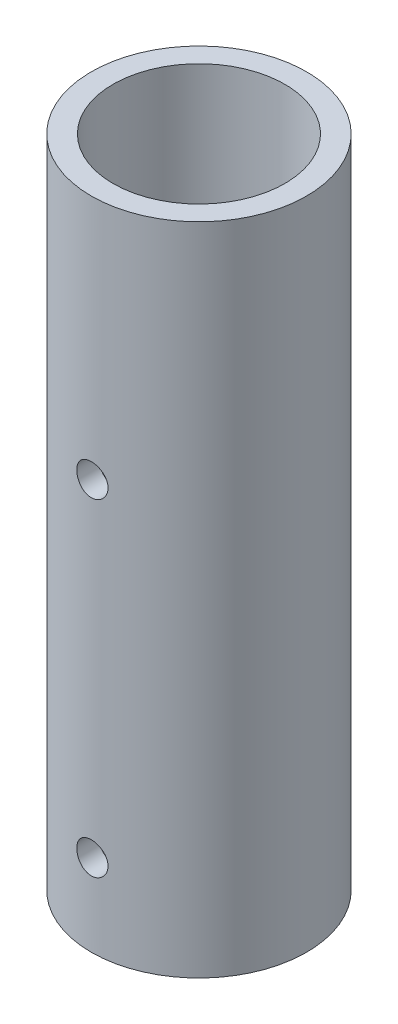
from build123d import *

# Parameters (mm, degrees)
SKETCH1_R               = 16.7005
SKETCH1_R_2             = 13.335
BOSS_EXTRUDE1_DEPTH     = 101.6
SKETCH2_R               = 2.4257
CUT_EXTRUDE1_DEPTH      = 17.7005
CUT_EXTRUDE1_DEPTH_BACK = 17.7005


with BuildPart() as part:
    # Sketch1 → Boss-Extrude1 (new body)
    with BuildSketch(Plane(origin=(0, 0, 0), x_dir=(1, 0, 0), z_dir=(0, 1, 0))):
        Circle(SKETCH1_R)
        Circle(SKETCH1_R_2, mode=Mode.SUBTRACT)
    extrude(amount=BOSS_EXTRUDE1_DEPTH)

    # Sketch2 → Cut-Extrude1 (cut, two sides)
    with BuildSketch(Plane.XY) as cut_extrude1_sk:
        with Locations((0, 63.5)):
            Circle(SKETCH2_R)
        with Locations((0, 12.7)):
            Circle(SKETCH2_R)
    extrude(amount=CUT_EXTRUDE1_DEPTH, mode=Mode.SUBTRACT)
    extrude(cut_extrude1_sk.sketch, amount=-CUT_EXTRUDE1_DEPTH_BACK, mode=Mode.SUBTRACT)


solid = part.part
